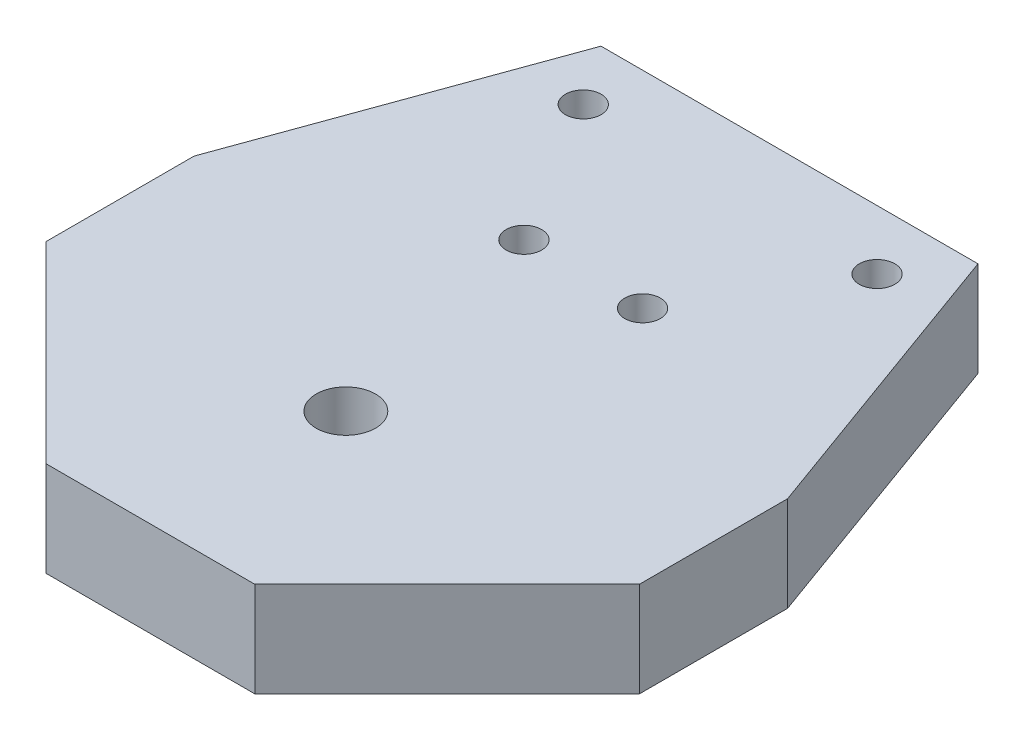
from build123d import *

# Parameters (mm, degrees)
SKETCH1_R           = 1.5
SKETCH1_R_2         = 2.5
BOSS_EXTRUDE1_DEPTH = 8


with BuildPart() as part:
    # Sketch1 → Boss-Extrude1 (new body)
    with BuildSketch(Plane(origin=(0, 0, 0), x_dir=(1, 0, 0), z_dir=(0, 1, 0))):
        Polygon((-8.795, -36.47), (8.795, -36.47), (25.001887425, -20.263112575), (25.001887425, -7.783112575), (15.88249732, 17.378899724), (-15.88249732, 17.378899724), (-25.001887425, -7.783112575), (-25.001887425, -20.263112575), align=None)
        with Locations((-5, 0)):
            Circle(SKETCH1_R, mode=Mode.SUBTRACT)
        with Locations((5, 0)):
            Circle(SKETCH1_R, mode=Mode.SUBTRACT)
        with Locations((0, -20)):
            Circle(SKETCH1_R_2, mode=Mode.SUBTRACT)
        with Locations((12.37637727, 12.378899724)):
            Circle(SKETCH1_R, mode=Mode.SUBTRACT)
        with Locations((-12.37637727, 12.378899724)):
            Circle(SKETCH1_R, mode=Mode.SUBTRACT)
    extrude(amount=BOSS_EXTRUDE1_DEPTH)


solid = part.part
